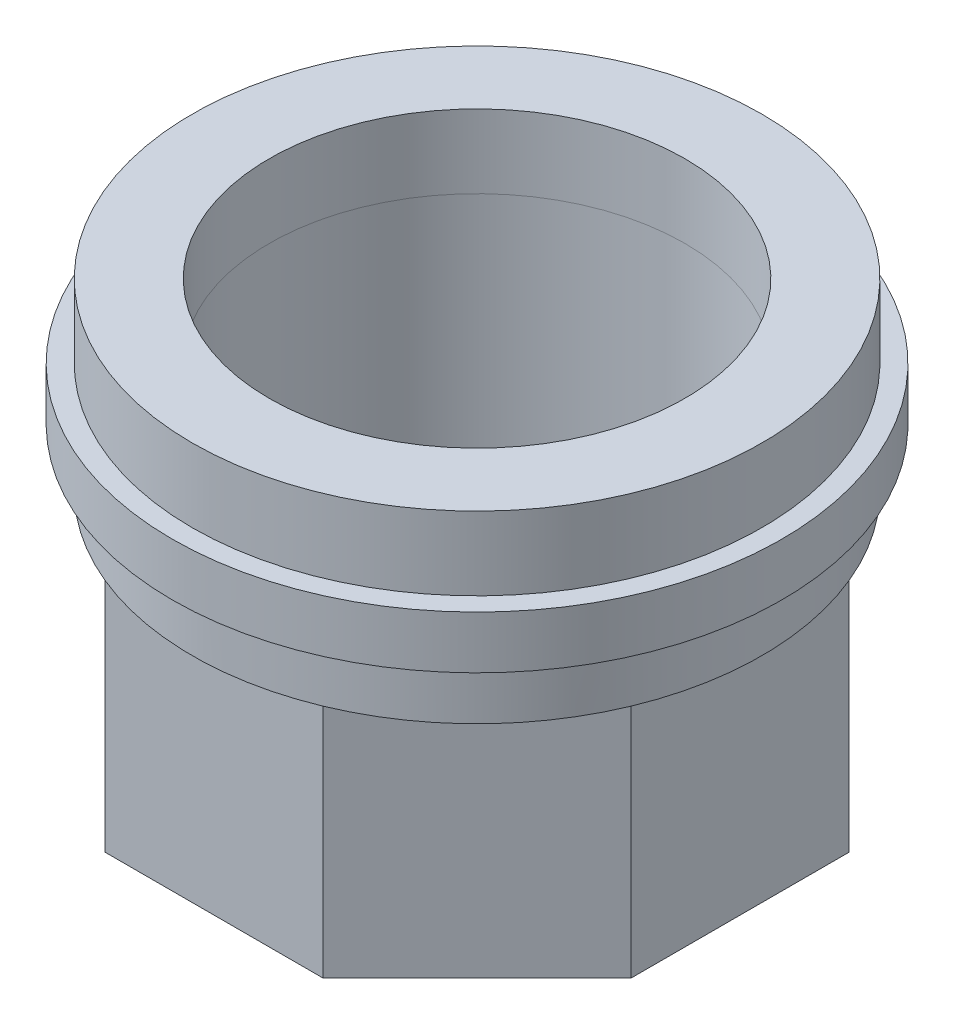
from build123d import *

# Parameters (mm, degrees)
ESBO_O1_R                = 15
RESSALTO_EXTRUS_O1_DEPTH = 17
ESBO_O2_R                = 20.565451806
ESBO_O2_R_2              = 15
RESSALTO_EXTRUS_O2_DEPTH = 4.2
ESBO_O3_R                = 22
ESBO_O3_R_2              = 15
RESSALTO_EXTRUS_O3_DEPTH = 3.8
ESBO_O4_R                = 20.565451806
ESBO_O4_R_2              = 15
RESSALTO_EXTRUS_O4_DEPTH = 5.3


with BuildPart() as part:
    # Esboço1 → Ressalto-extrusão1 (new body)
    with BuildSketch(Plane(origin=(0, 0, 0), x_dir=(1, 0, 0), z_dir=(0, 1, 0))):
        Polygon((7.870057685, -19), (19, -7.870057685), (19, 7.870057685), (7.870057685, 19), (-7.870057685, 19), (-19, 7.870057685), (-19, -7.870057685), (-7.870057685, -19), align=None)
        Circle(ESBO_O1_R, mode=Mode.SUBTRACT)
    extrude(amount=RESSALTO_EXTRUS_O1_DEPTH)

    # Esboço2 → Ressalto-extrusão2 (add)
    with BuildSketch(Plane(origin=(0, 17, 0), x_dir=(1, 0, 0), z_dir=(0, 1, 0))):
        Circle(ESBO_O2_R)
        Circle(ESBO_O2_R_2, mode=Mode.SUBTRACT)
    extrude(amount=RESSALTO_EXTRUS_O2_DEPTH)

    # Esboço3 → Ressalto-extrusão3 (add)
    with BuildSketch(Plane(origin=(0, 21.2, 0), x_dir=(1, 0, 0), z_dir=(0, 1, 0))):
        Circle(ESBO_O3_R)
        Circle(ESBO_O3_R_2, mode=Mode.SUBTRACT)
    extrude(amount=RESSALTO_EXTRUS_O3_DEPTH)


with BuildPart() as body_2:
    # Esboço4 → Ressalto-extrusão4 (new body)
    with BuildSketch(Plane(origin=(0, 25, 0), x_dir=(1, 0, 0), z_dir=(0, 1, 0))):
        Circle(ESBO_O4_R)
        Circle(ESBO_O4_R_2, mode=Mode.SUBTRACT)
    extrude(amount=RESSALTO_EXTRUS_O4_DEPTH)


solid = Compound([part.part, body_2.part])
